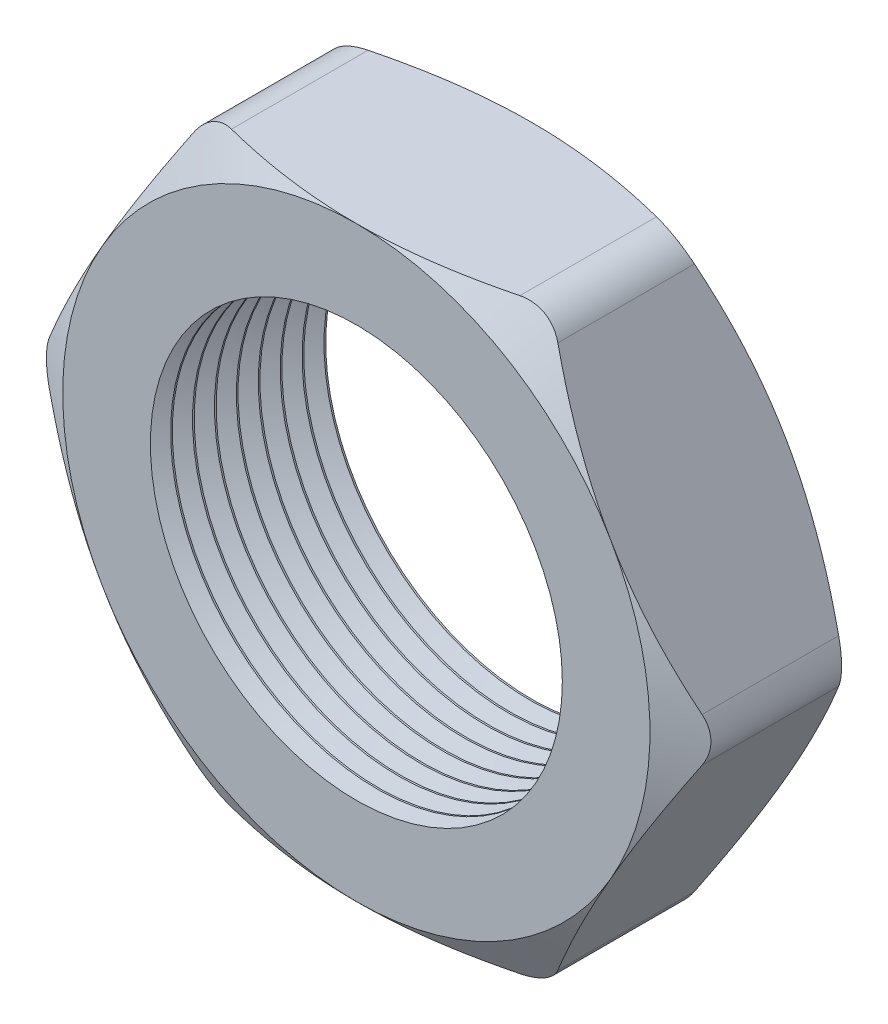
from build123d import *

# Parameters (mm, degrees)
SKETCH1_R          = 5.969
EXTRUDE1_DEPTH     = 5.08
SKETCH2_OUTSIDE_W  = 48.01
SKETCH2_OUTSIDE_H  = 45.378
SKETCH2_OUTSIDE_R  = 8.509
CUT_EXTRUDE1_DEPTH = 6.08
CUT_EXTRUDE1_DRAFT = -60
SKETCH3_OUTSIDE_W  = 48.01
SKETCH3_OUTSIDE_H  = 45.378
SKETCH3_OUTSIDE_R  = 8.509
CUT_EXTRUDE2_DEPTH = 6.08
CUT_EXTRUDE2_DRAFT = -60
FILLET1_R          = 1.27
LPATTERN1_COUNT    = 8
LPATTERN1_PITCH    = 0.635


with BuildPart() as part:
    # Sketch1 → Extrude1 (new body)
    with BuildSketch(Plane.XY):
        Polygon((-9.825346881, 0), (-4.912673441, -8.509), (4.912673441, -8.509), (9.825346881, 0), (4.912673441, 8.509), (-4.912673441, 8.509), align=None)
        Circle(SKETCH1_R, mode=Mode.SUBTRACT)
    extrude(amount=EXTRUDE1_DEPTH)


with BuildPart() as cut_extrude1_tool:
    # Sketch2 outside → Cut-Extrude1 (with draft: the straight prism first)
    with BuildSketch(Plane.XY.offset(5.08)):
        Rectangle(SKETCH2_OUTSIDE_W, SKETCH2_OUTSIDE_H)
        Circle(SKETCH2_OUTSIDE_R, mode=Mode.SUBTRACT)
    extrude(amount=-CUT_EXTRUDE1_DEPTH)
    # Cut-Extrude1: the draft: its side faces are tilted about the plane it starts from
    cut_extrude1_sides = [cut_extrude1_tool.faces().sort_by_distance(p)[0] for p in [
        (0, -22.689, 2.04),
        (24.005, 0, 2.04),
        (0, 22.689, 2.04),
        (-24.005, 0, 2.04),
        (-8.509, 0, 2.04),
    ]]
    draft(cut_extrude1_sides, Plane.XY.offset(5.08), CUT_EXTRUDE1_DRAFT)


with BuildPart() as part_1:
    add(part.part)

    # Cut-Extrude1: cut by cut_extrude1_tool
    add(cut_extrude1_tool.part, mode=Mode.SUBTRACT)


with BuildPart() as cut_extrude2_tool:
    # Sketch3 outside → Cut-Extrude2 (with draft: the straight prism first)
    with BuildSketch(Plane(origin=(0, 0, 0), x_dir=(-1, 0, 0), z_dir=(0, 0, -1))):
        Rectangle(SKETCH3_OUTSIDE_W, SKETCH3_OUTSIDE_H)
        Circle(SKETCH3_OUTSIDE_R, mode=Mode.SUBTRACT)
    extrude(amount=-CUT_EXTRUDE2_DEPTH)
    # Cut-Extrude2: the draft: its side faces are tilted about the plane it starts from
    cut_extrude2_sides = [cut_extrude2_tool.faces().sort_by_distance(p)[0] for p in [
        (0, -22.689, 3.04),
        (-24.005, 0, 3.04),
        (0, 22.689, 3.04),
        (24.005, 0, 3.04),
        (8.509, 0, 3.04),
    ]]
    draft(cut_extrude2_sides, Plane(origin=(0, 0, 0), x_dir=(-1, 0, 0), z_dir=(0, 0, -1)), CUT_EXTRUDE2_DRAFT)


with BuildPart() as part_2:
    add(part_1.part)

    # Cut-Extrude2: cut by cut_extrude2_tool
    add(cut_extrude2_tool.part, mode=Mode.SUBTRACT)

    # Fillet1
    fillet1_edges = [part_2.edges().sort_by_distance(p)[0] for p in [
        (9.825346881, 0, 2.54),
        (4.912673441, -8.509, 2.54),
        (-4.912673441, -8.509, 2.54),
        (-9.825346881, 0, 2.54),
        (-4.912673441, 8.509, 2.54),
        (4.912673441, 8.509, 2.54),
    ]]
    fillet(fillet1_edges, radius=FILLET1_R)

    # Sketch4 → Cut-Revolve1 (revolve, cut)
    with BuildSketch(Plane(origin=(0, 0, 0), x_dir=(1, 0, 0), z_dir=(0, 1, 0)), mode=Mode.PRIVATE) as cut_revolve1_sk:
        Polygon((-5.969, -5.08), (-5.969, -4.493412127), (-6.477, -4.786706063), align=None)
    cut_revolve1 = revolve(cut_revolve1_sk.sketch.rotate(Axis((0, 0, 0), (0, 0, 1)), 180), axis=Axis((0, 0, 0), (0, 0, 1)), mode=Mode.SUBTRACT)  # turned: the seam where the file's is

    # LPattern1: Cut-Revolve1 ×8
    with Locations(*[(0, 0, -i * LPATTERN1_PITCH) for i in range(1, LPATTERN1_COUNT)]):
        add(cut_revolve1, mode=Mode.SUBTRACT)


solid = part_2.part
